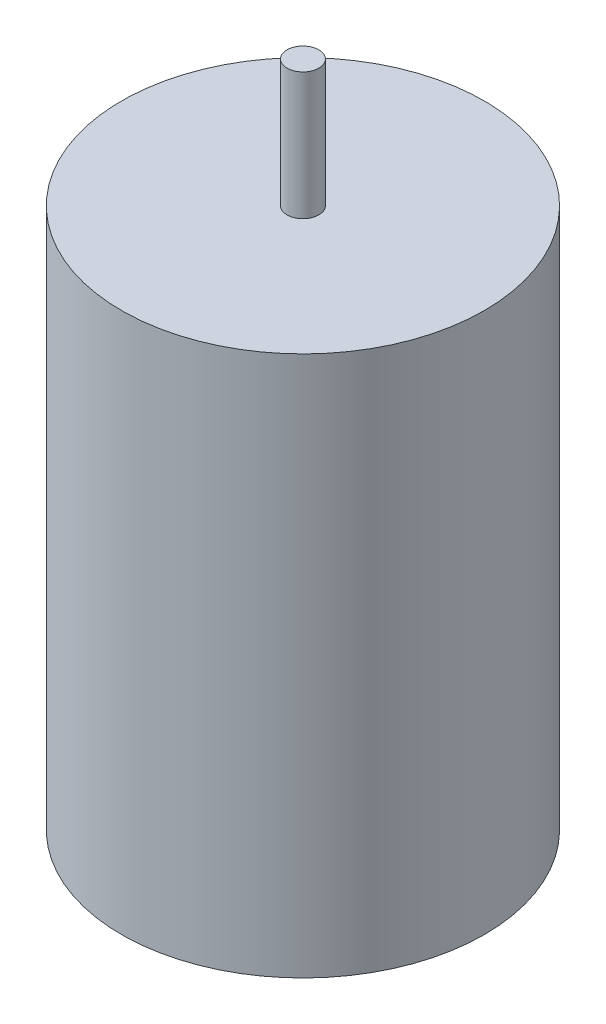
from build123d import *


with BuildPart() as part:
    # Sketch1 → Revolve1 (revolve)
    with BuildSketch(Plane.XY):
        Polygon((0, 66.7), (1.5875, 66.7), (1.5875, 54), (18.1316, 54), (18.1316, 0), (0, 0), align=None)
    revolve(axis=Axis((0, -66.7, 0), (0, 1, 0)))


solid = part.part
